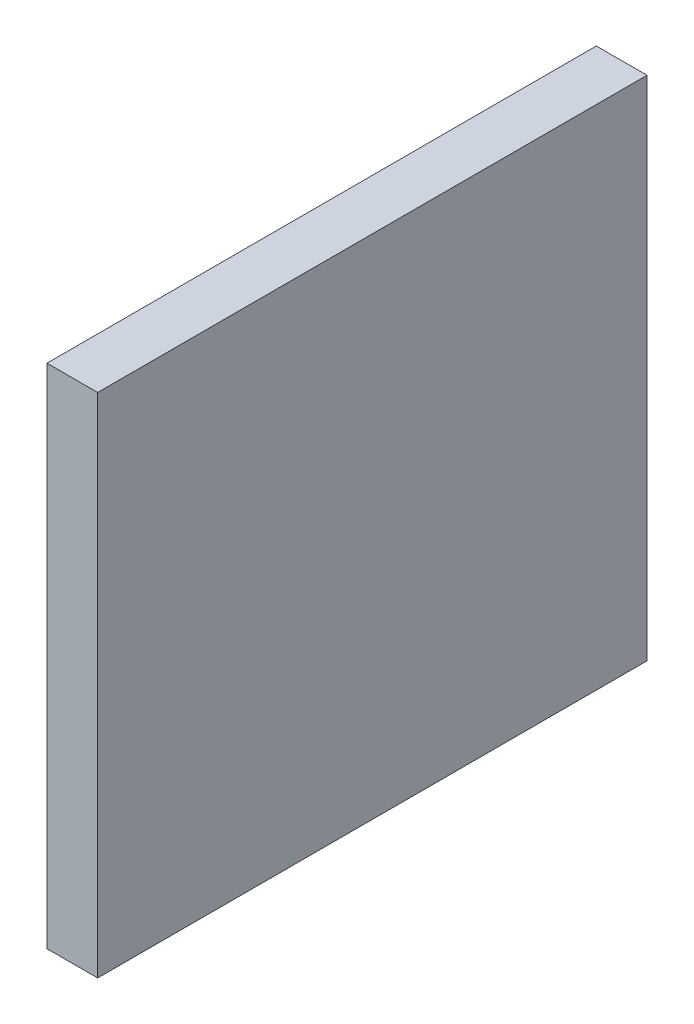
from build123d import *

# Parameters (mm, degrees)
SKETCH1_W           = 3
SKETCH1_H           = 32.5
BOSS_EXTRUDE1_DEPTH = 30


with BuildPart() as part:
    # Sketch1 → Boss-Extrude1 (new body)
    with BuildSketch(Plane(origin=(0, 0, 0), x_dir=(1, 0, 0), z_dir=(0, 1, 0))):
        with Locations((-53.242861362, -17.926104556)):
            Rectangle(SKETCH1_W, SKETCH1_H)
    extrude(amount=-BOSS_EXTRUDE1_DEPTH)


solid = part.part
